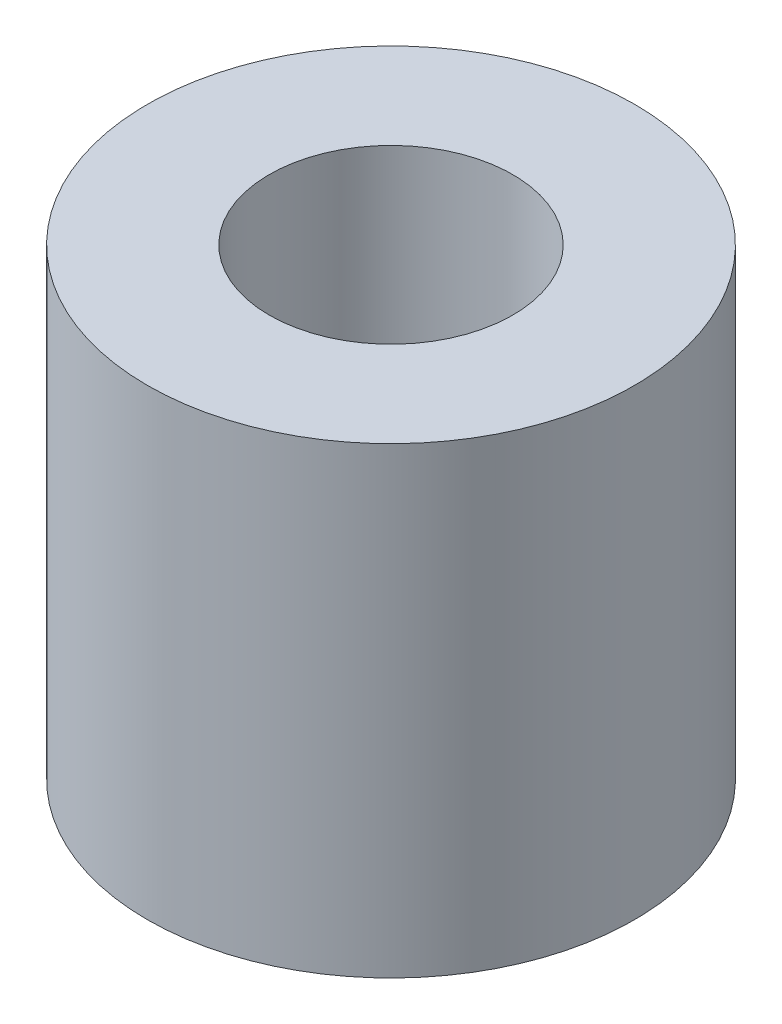
from build123d import *

# Parameters (mm, degrees)
SKETCH2_R           = 5.08
SKETCH2_R_2         = 2.54
BOSS_EXTRUDE1_DEPTH = 9.652


with BuildPart() as part:
    # Sketch2 → Boss-Extrude1 (new body)
    with BuildSketch(Plane(origin=(0, 0, 0), x_dir=(1, 0, 0), z_dir=(0, 1, 0))):
        Circle(SKETCH2_R)
        Circle(SKETCH2_R_2, mode=Mode.SUBTRACT)
    extrude(amount=BOSS_EXTRUDE1_DEPTH)


solid = part.part
